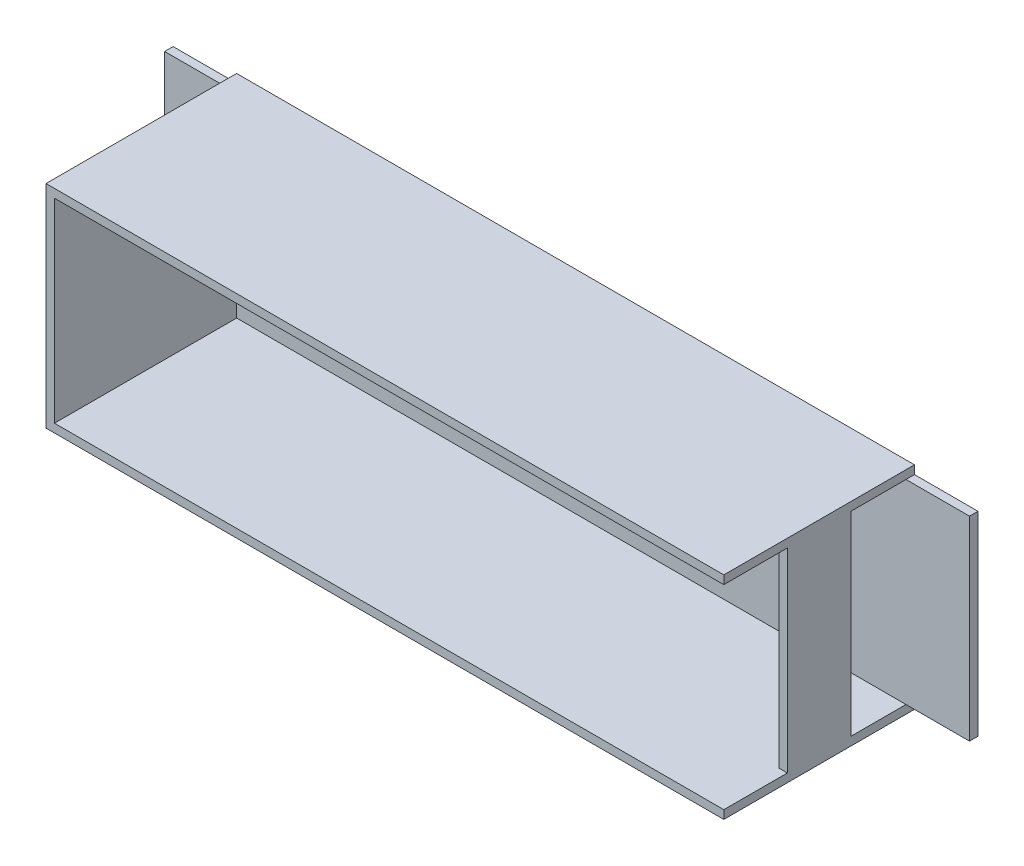
from build123d import *

# Parameters (mm, degrees)
ESBO_O1_W                = 160
ESBO_O1_H                = 50
RESSALTO_EXTRUS_O1_DEPTH = 45
ESBO_O3_W                = 2
ESBO_O3_H                = 46
RESSALTO_EXTRUS_O2_DEPTH = 15
ESBO_O9_W                = 156
ESBO_O9_H                = 46
CORTE_EXTRUS_O2_DEPTH    = 43
CORTE_EXTRUS_O3_REACH    = 162
ESBO_O10_W               = 15
ESBO_O10_H               = 46
ESBO_O10_W_2             = 13
ESBO_O11_W               = 2
ESBO_O11_H               = 46
RESSALTO_EXTRUS_O6_DEPTH = 15


with BuildPart() as part:
    # Esboço1 → Ressalto-extrusão1 (new body)
    with BuildSketch(Plane.XY):
        Rectangle(ESBO_O1_W, ESBO_O1_H)
    extrude(amount=RESSALTO_EXTRUS_O1_DEPTH)

    # Esboço3 → Ressalto-extrusão2 (add)
    with BuildSketch(Plane(origin=(80, 0, 0), x_dir=(0, 0, -1), z_dir=(1, 0, 0))):
        with Locations((-1, 0)):
            Rectangle(ESBO_O3_W, ESBO_O3_H)
    extrude(amount=RESSALTO_EXTRUS_O2_DEPTH)

    # Esboço9 → Corte-extrusão2 (cut)
    with BuildSketch(Plane.XY.offset(45)):
        Rectangle(ESBO_O9_W, ESBO_O9_H)
    extrude(amount=-CORTE_EXTRUS_O2_DEPTH, mode=Mode.SUBTRACT)

    # Esboço10 → Corte-extrusão3 (cut, up to next)
    with BuildSketch(Plane(origin=(80, 0, 0), x_dir=(0, 0, -1), z_dir=(1, 0, 0)), mode=Mode.PRIVATE) as corte_extrus_o3_sk1:
        with Locations((-37.5, 0)):
            Rectangle(ESBO_O10_W, ESBO_O10_H)
    corte_extrus_o3_tool1 = extrude(corte_extrus_o3_sk1.sketch, amount=-CORTE_EXTRUS_O3_REACH, mode=Mode.PRIVATE) & part.part
    add(corte_extrus_o3_tool1.solids().sort_by_distance((80, 0, 37.5))[0], mode=Mode.SUBTRACT)
    # Esboço10 → Corte-extrusão3 (cut, up to next)
    with BuildSketch(Plane(origin=(80, 0, 0), x_dir=(0, 0, -1), z_dir=(1, 0, 0)), mode=Mode.PRIVATE) as corte_extrus_o3_sk2:
        with Locations((-8.5, 0)):
            Rectangle(ESBO_O10_W_2, ESBO_O10_H)
    corte_extrus_o3_tool2 = extrude(corte_extrus_o3_sk2.sketch, amount=-CORTE_EXTRUS_O3_REACH, mode=Mode.PRIVATE) & part.part
    add(corte_extrus_o3_tool2.solids().sort_by_distance((80, 0, 8.5))[0], mode=Mode.SUBTRACT)

    # Esboço11 → Ressalto-extrusão6 (add)
    with BuildSketch(Plane.ZY.offset(80)):
        with Locations((1, 0)):
            Rectangle(ESBO_O11_W, ESBO_O11_H)
    extrude(amount=RESSALTO_EXTRUS_O6_DEPTH)


solid = part.part
